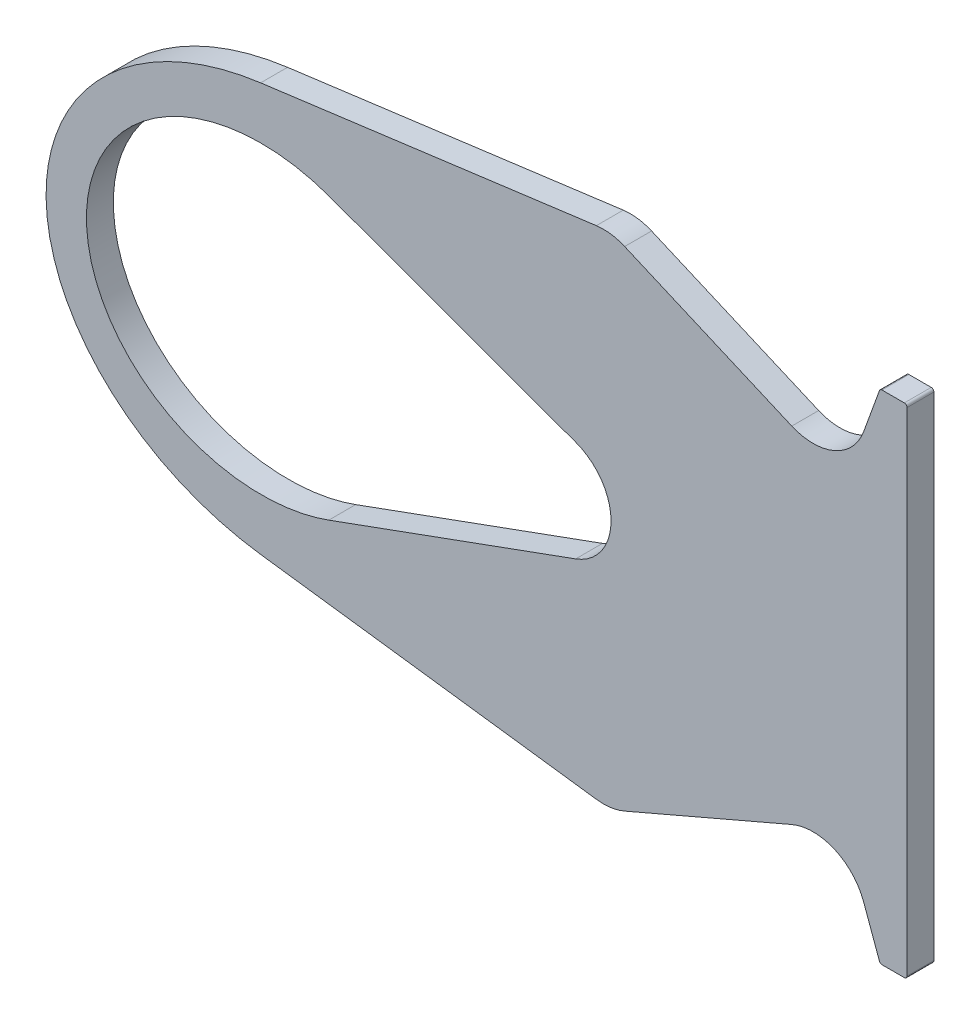
from build123d import *

# Parameters (mm, degrees)
EXTRUDE1_DEPTH = 10


with BuildPart() as part:
    # Sketch1 → Extrude1 (new body)
    with BuildSketch(Plane.XY):
        with BuildLine():
            Line((-1, -92.5), (-9.299792462, -92.5))
            ThreePointArc((-9.299792462, -92.5), (-9.873368898, -92.319152044), (-10.239485083, -91.842020143))
            Line((-10.239485083, -91.842020143), (-16.129405376, -75.659597133))
            ThreePointArc((-16.129405376, -75.659597133), (-26.995229889, -64.138453944), (-42.831985033, -64.13013246))
            Line((-42.831985033, -64.13013246), (-104.941269692, -90.86986754))
            ThreePointArc((-104.941269692, -90.86986754), (-110.102283026, -92.310352553), (-115.460520777, -92.328897227))
            Line((-115.460520777, -92.328897227), (-240.250906006, -75.899931337))
            add(Edge.make_bspline(
                [(-240.250906006, 75.899931337), (-320, 65.400763933), (-320, 0), (-320, -65.400763933), (-240.250906006, -75.899931337)],
                knots=[1.73202985, 1.73202985, 1.73202985, 3.141592654, 3.141592654, 4.551155457, 4.551155457, 4.551155457], degree=2, weights=[1, 0.761753193, 1, 0.761753193, 1]))
            Line((-240.250906006, 75.899931337), (-115.460520777, 92.328897227))
            ThreePointArc((-115.460520777, 92.328897227), (-110.102283026, 92.310352553), (-104.941269692, 90.86986754))
            Line((-104.941269692, 90.86986754), (-42.831985033, 64.13013246))
            ThreePointArc((-42.831985033, 64.13013246), (-26.995229889, 64.138453944), (-16.129405376, 75.659597133))
            Line((-16.129405376, 75.659597133), (-10.239485083, 91.842020143))
            ThreePointArc((-10.239485083, 91.842020143), (-9.873368898, 92.319152044), (-9.299792462, 92.5))
            Line((-9.299792462, 92.5), (-1, 92.5))
            ThreePointArc((-1, 92.5), (-0.292893219, 92.207106781), (0, 91.5))
            Line((0, 91.5), (0, -91.5))
            ThreePointArc((0, -91.5), (-0.292893219, -92.207106781), (-1, -92.5))
        make_face()
        with BuildLine():
            Line((-214.922257217, -52.192729303), (-123.159597133, -18.793852416))
            ThreePointArc((-123.159597133, -18.793852416), (-110, 0), (-123.159597133, 18.793852416))
            Line((-123.159597133, 18.793852416), (-214.922257217, 52.192729303))
            add(Edge.make_bspline(
                [(-214.922257217, 52.192729303), (-305, 84.978346446), (-305, 0), (-305, -84.978346446), (-214.922257217, -52.192729303)],
                knots=[1.174709144, 1.174709144, 1.174709144, 3.141592654, 3.141592654, 5.108476163, 5.108476163, 5.108476163], degree=2, weights=[1, 0.554160885, 1, 0.554160885, 1]))
        make_face(mode=Mode.SUBTRACT)
    extrude(amount=EXTRUDE1_DEPTH)


solid = part.part
